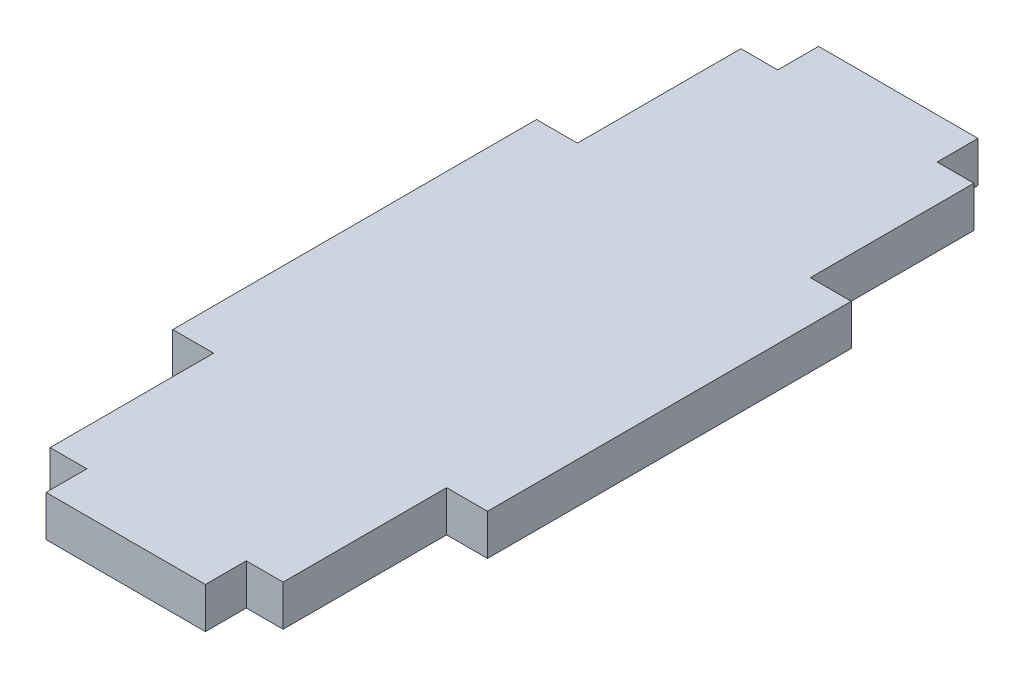
from build123d import *

# Parameters (mm, degrees)
BOSS_EXTRUDE1_DEPTH = 5


with BuildPart() as part:
    # Sketch1 → Boss-Extrude1 (new body)
    with BuildSketch(Plane(origin=(0, 0, 0), x_dir=(1, 0, 0), z_dir=(0, 1, 0))):
        Polygon((-14.25, 42.25), (-9.75, 42.25), (-9.75, 47.25), (9.75, 47.25), (9.75, 42.25), (14.25, 42.25), (14.25, 22.25), (19.25, 22.25), (19.25, -22.25), (14.25, -22.25), (14.25, -42.25), (9.75, -42.25), (9.75, -47.25), (-9.75, -47.25), (-9.75, -42.25), (-14.25, -42.25), (-14.25, -22.25), (-19.25, -22.25), (-19.25, 22.25), (-14.25, 22.25), align=None)
    extrude(amount=BOSS_EXTRUDE1_DEPTH)


solid = part.part
